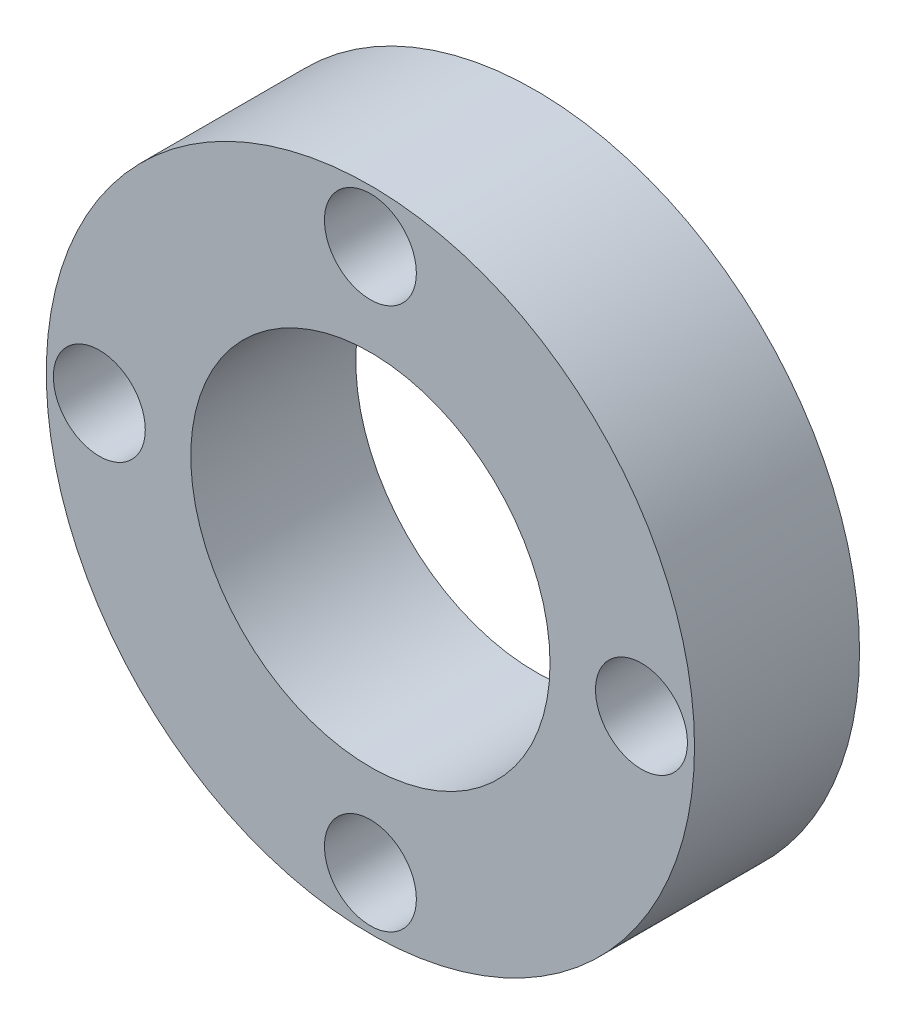
from build123d import *

# Parameters (mm, degrees)
SKETCH1_R           = 13.75
SKETCH1_R_2         = 7.62
BOSS_EXTRUDE1_DEPTH = 7
CUT_EXTRUDE1_REACH  = 9
SKETCH3_R           = 1.9499961


with BuildPart() as part:
    # Sketch1 → Boss-Extrude1 (new body)
    with BuildSketch(Plane.XY):
        Circle(SKETCH1_R)
        Circle(SKETCH1_R_2, mode=Mode.SUBTRACT)
    extrude(amount=-BOSS_EXTRUDE1_DEPTH)

    # Sketch3 → Cut-Extrude1 (cut, up to next)
    with BuildSketch(Plane.XY, mode=Mode.PRIVATE) as cut_extrude1_sk1:
        with Locations((-11.49999986, 0)):
            Circle(SKETCH3_R)
    cut_extrude1_tool1 = extrude(cut_extrude1_sk1.sketch, amount=-CUT_EXTRUDE1_REACH, mode=Mode.PRIVATE) & part.part
    add(cut_extrude1_tool1.solids().sort_by_distance((-11.5, 0, 0))[0], mode=Mode.SUBTRACT)
    # Sketch3 → Cut-Extrude1 (cut, up to next)
    with BuildSketch(Plane.XY, mode=Mode.PRIVATE) as cut_extrude1_sk2:
        with Locations((0, 11.49999986)):
            Circle(SKETCH3_R)
    cut_extrude1_tool2 = extrude(cut_extrude1_sk2.sketch, amount=-CUT_EXTRUDE1_REACH, mode=Mode.PRIVATE) & part.part
    add(cut_extrude1_tool2.solids().sort_by_distance((0, 11.5, 0))[0], mode=Mode.SUBTRACT)
    # Sketch3 → Cut-Extrude1 (cut, up to next)
    with BuildSketch(Plane.XY, mode=Mode.PRIVATE) as cut_extrude1_sk3:
        with Locations((11.49999986, 0)):
            Circle(SKETCH3_R)
    cut_extrude1_tool3 = extrude(cut_extrude1_sk3.sketch, amount=-CUT_EXTRUDE1_REACH, mode=Mode.PRIVATE) & part.part
    add(cut_extrude1_tool3.solids().sort_by_distance((11.5, 0, 0))[0], mode=Mode.SUBTRACT)
    # Sketch3 → Cut-Extrude1 (cut, up to next)
    with BuildSketch(Plane.XY, mode=Mode.PRIVATE) as cut_extrude1_sk4:
        with Locations((0, -11.49999986)):
            Circle(SKETCH3_R)
    cut_extrude1_tool4 = extrude(cut_extrude1_sk4.sketch, amount=-CUT_EXTRUDE1_REACH, mode=Mode.PRIVATE) & part.part
    add(cut_extrude1_tool4.solids().sort_by_distance((0, -11.5, 0))[0], mode=Mode.SUBTRACT)


solid = part.part
